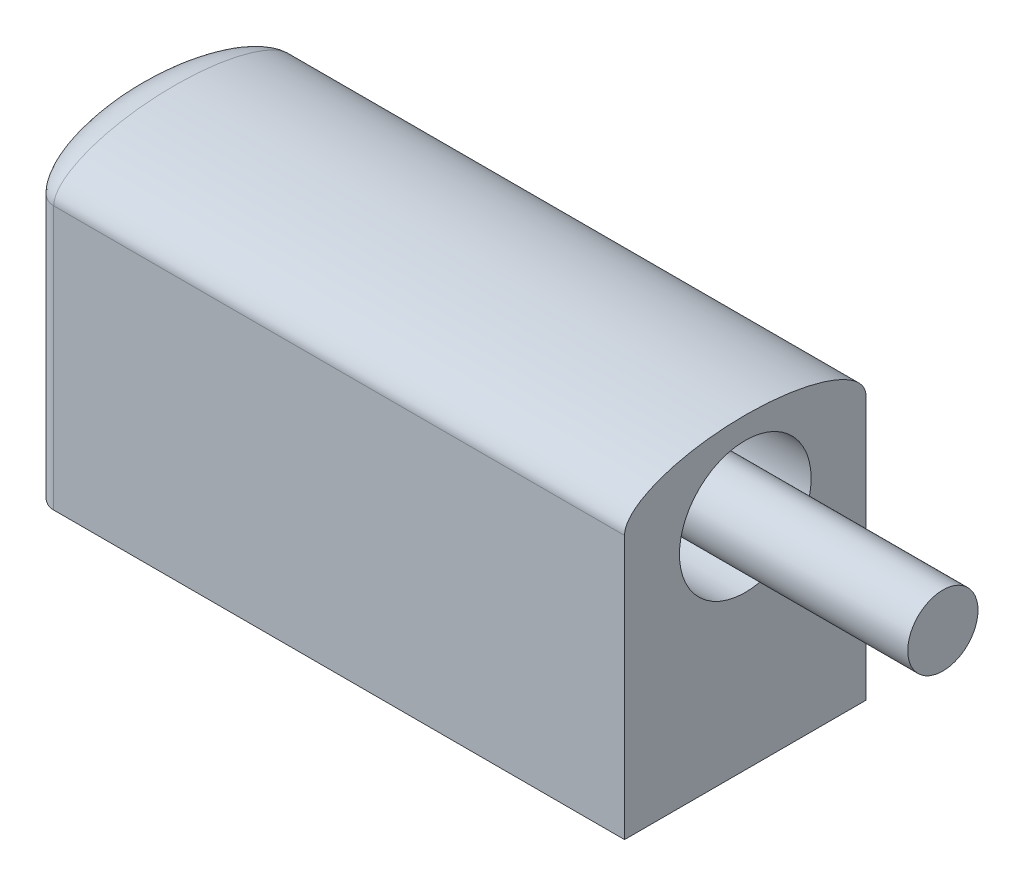
from build123d import *

# Parameters (mm, degrees)
CROQUIS1_W              = 26
CROQUIS1_H              = 12
SALIENTE_EXTRUIR1_DEPTH = 11
CROQUIS5_RX             = 5.5
CROQUIS5_RY             = 2
SALIENTE_EXTRUIR2_DEPTH = 26
CROQUIS6_RX             = 5.5
CROQUIS6_RY             = 2
SALIENTE_EXTRUIR3_DEPTH = 12
REVOLUCI_N2_ANGLE       = 90
CROQUIS9_R              = 3
CORTAR_EXTRUIR1_DEPTH   = 5
CROQUIS11_R             = 1.6
SALIENTE_EXTRUIR4_DEPTH = 14
CROQUIS12_R             = 2.1
CORTAR_EXTRUIR2_DEPTH   = 6


with BuildPart() as part:
    # Croquis1 → Saliente-Extruir1 (new body)
    with BuildSketch(Plane.XY):
        with Locations((-1.484877735, 3.639455782)):
            Rectangle(CROQUIS1_W, CROQUIS1_H)
    extrude(amount=SALIENTE_EXTRUIR1_DEPTH)

    # Croquis5 → Saliente-Extruir2 (add)
    with BuildSketch(Plane(origin=(11.515122265, 0, 0), x_dir=(0, 0, -1), z_dir=(1, 0, 0))):
        with Locations((-5.5, 9.639455782)):
            Ellipse(CROQUIS5_RX, CROQUIS5_RY)
    extrude(amount=-SALIENTE_EXTRUIR2_DEPTH)

    # Croquis6 → Saliente-Extruir3 (add)
    with BuildSketch(Plane.XZ.offset(2.360544218)):
        with Locations(Location((-14.484877735, 5.5), (0, 0, -90))):
            Ellipse(CROQUIS6_RX, CROQUIS6_RY)
    extrude(amount=-SALIENTE_EXTRUIR3_DEPTH)

    # Croquis8 → Revolución2 (revolve)
    with BuildSketch(Plane.ZY.offset(14.484877735)):
        with BuildLine():
            Line((0, 9.639455782), (11, 9.639455782))
            add(Edge.make_bspline(
                [(11, 9.639455782), (11, 11.639455782), (5.5, 11.639455782), (0, 11.639455782), (0, 9.639455782)],
                knots=[3.141592654, 3.141592654, 3.141592654, 4.71238898, 4.71238898, 6.283185307, 6.283185307, 6.283185307], degree=2, weights=[1, 0.707106781, 1, 0.707106781, 1]))
        make_face()
    revolve(axis=Axis((-14.484877735, 9.639455782, 0), (0, 0, 1)), revolution_arc=REVOLUCI_N2_ANGLE)

    # Croquis9 → Cortar-Extruir1 (cut)
    with BuildSketch(Plane(origin=(11.515122265, 0, 0), x_dir=(0, 0, -1), z_dir=(1, 0, 0))):
        with Locations((-5.5, 7.639455782)):
            Circle(CROQUIS9_R)
    extrude(amount=-CORTAR_EXTRUIR1_DEPTH, mode=Mode.SUBTRACT)

    # Croquis11 → Saliente-Extruir4 (add)
    with BuildSketch(Plane(origin=(6.515122265, 0, 0), x_dir=(0, 0, -1), z_dir=(1, 0, 0))):
        with Locations((-5.5, 7.639455782)):
            Circle(CROQUIS11_R)
    extrude(amount=SALIENTE_EXTRUIR4_DEPTH)

    # Croquis12 → Cortar-Extruir2 (cut)
    with BuildSketch(Plane.XZ.offset(2.360544218)):
        with Locations((1.515122265, 5.5)):
            Circle(CROQUIS12_R)
        with Locations((-6.484877735, 5.5)):
            Circle(CROQUIS12_R)
    extrude(amount=-CORTAR_EXTRUIR2_DEPTH, mode=Mode.SUBTRACT)


solid = part.part
